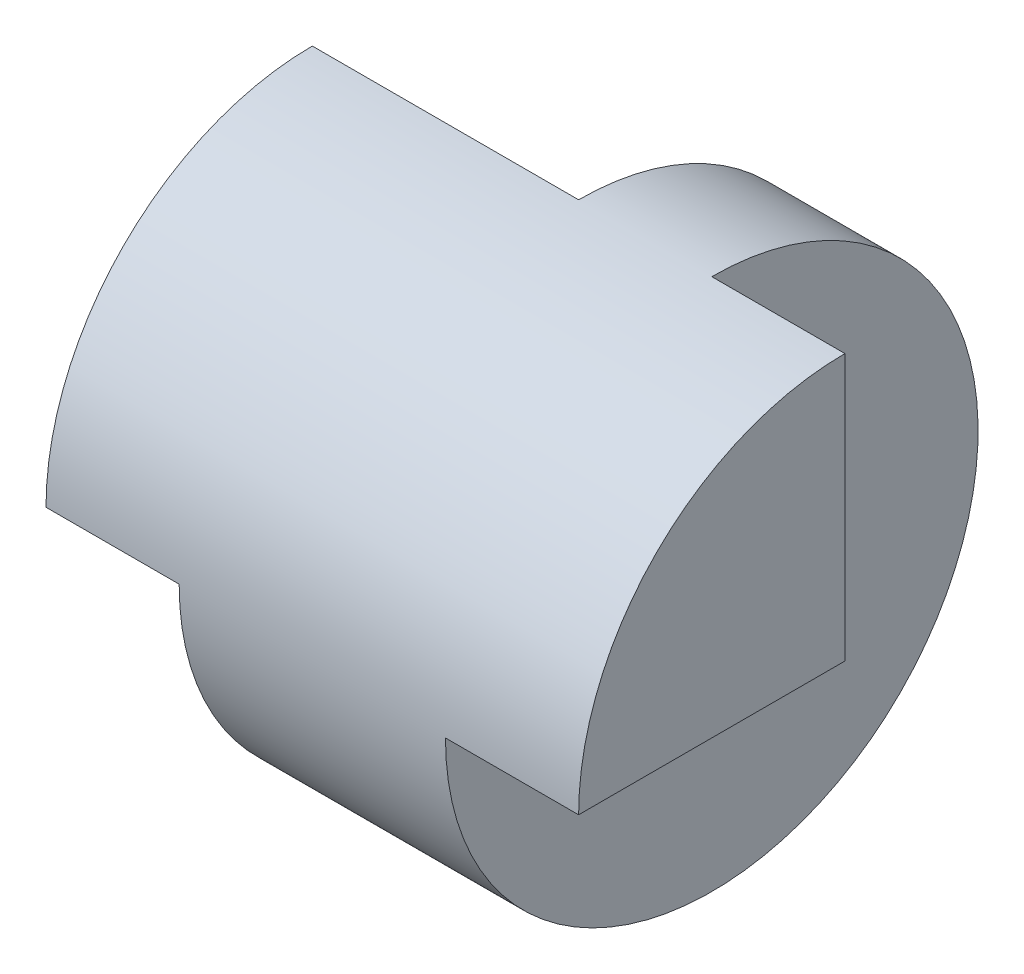
from build123d import *

# Parameters (mm, degrees)
SKETCH5_W          = 4
SKETCH5_H          = 2
SKETCH6_W          = 1
SKETCH6_H          = 2
CUT_EXTRUDE5_DEPTH = 5.5
SKETCH7_W          = 2
SKETCH7_H          = 2
SKETCH7_W_2        = 1
CUT_EXTRUDE6_DEPTH = 10


with BuildPart() as part:
    # Sketch5 → Revolve-Thin2 (revolve)
    with BuildSketch(Plane.XY):
        with Locations((2, 1)):
            Rectangle(SKETCH5_W, SKETCH5_H)
    revolve(axis=Axis((0, 0, 0), (1, 0, 0)))

    # Sketch6 → Cut-Extrude5 (cut, symmetric)
    with BuildSketch(Plane.XY):
        with Locations((3.5, -1)):
            Rectangle(SKETCH6_W, SKETCH6_H)
        with Locations((0.5, -1)):
            Rectangle(SKETCH6_W, SKETCH6_H)
    extrude(amount=CUT_EXTRUDE5_DEPTH, both=True, mode=Mode.SUBTRACT)

    # Sketch7 → Cut-Extrude6 (cut)
    with BuildSketch(Plane.XZ):
        with Locations((1, -1)):
            Rectangle(SKETCH7_W, SKETCH7_H)
        with Locations((3.5, -1)):
            Rectangle(SKETCH7_W_2, SKETCH7_H)
    extrude(amount=-CUT_EXTRUDE6_DEPTH, mode=Mode.SUBTRACT)


solid = part.part
